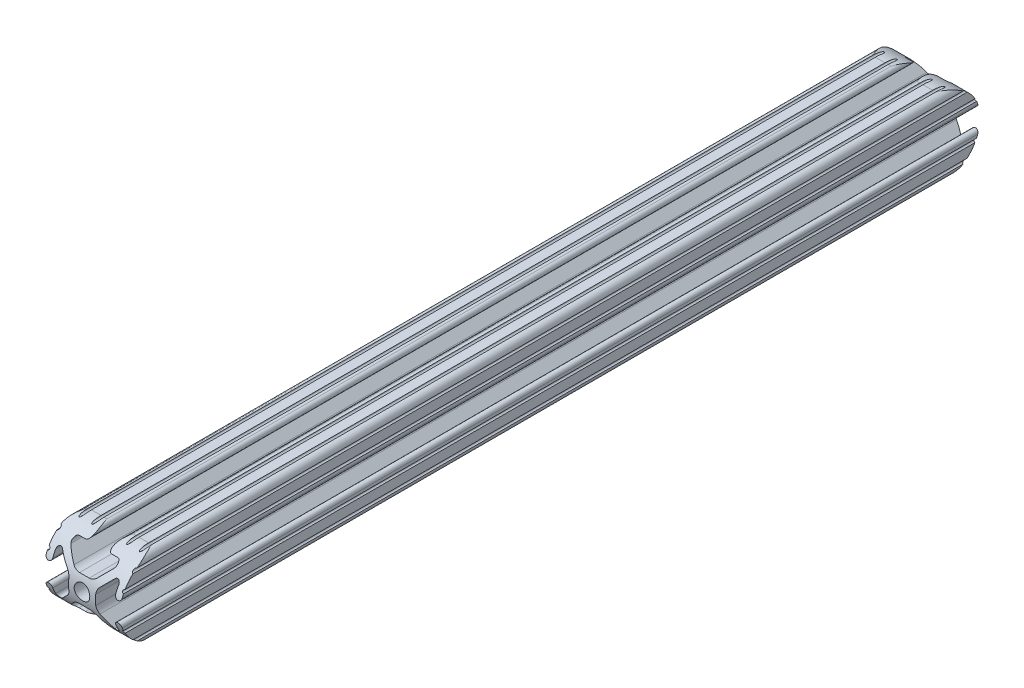
from build123d import *

# Parameters (mm, degrees)
SKETCH1_R           = 2.6035
BOSS_EXTRUDE1_DEPTH = 287.02
CUT_EXTRUDE1_DEPTH  = 26.4


with BuildPart() as part:
    # Sketch1 → Boss-Extrude1 (new body)
    with BuildSketch(Plane(origin=(0, 0, -450.85), x_dir=(-1, 0, 0), z_dir=(0, 0, -1))):
        with BuildLine():
            Line((12.7, -9.5504), (12.7, -6.3330836))
            ThreePointArc((12.7, -6.3330836), (12.192, -5.8250836), (12.7, -5.3170836))
            Line((12.7, -5.3170836), (12.7, -4.3434))
            ThreePointArc((12.7, -4.3434), (11.5951, -3.2385), (10.4902, -4.3434))
            Line((10.4902, -4.3434), (10.4902, -6.474794456))
            ThreePointArc((10.4902, -6.474794456), (9.863006367, -7.413456061), (8.75577951, -7.193214945))
            Line((8.75577951, -7.193214945), (5.42573597, -3.863171405))
            ThreePointArc((5.42573597, -3.863171405), (4.737482484, -2.833127272), (4.4958, -1.618107374))
            Line((4.4958, -1.618107374), (4.4958, 1.618107374))
            ThreePointArc((4.4958, 1.618107374), (4.737482484, 2.833127272), (5.42573597, 3.863171405))
            Line((5.42573597, 3.863171405), (8.75577951, 7.193214945))
            ThreePointArc((8.75577951, 7.193214945), (9.863006367, 7.413456061), (10.4902, 6.474794456))
            Line((10.4902, 6.474794456), (10.4902, 4.343399971))
            ThreePointArc((10.4902, 4.343399971), (11.5951, 3.238499971), (12.7, 4.343399971))
            Line((12.7, 4.343399971), (12.7, 5.3170836))
            ThreePointArc((12.7, 5.3170836), (12.192, 5.8250836), (12.7, 6.3330836))
            Line((12.7, 6.3330836), (12.7, 9.5504))
            ThreePointArc((12.7, 9.5504), (12.192000006, 10.058323491), (12.699846982, 10.566399977))
            ThreePointArc((12.699846982, 10.566399977), (12.082522516, 12.082522516), (10.566399977, 12.699846982))
            ThreePointArc((10.566399977, 12.699846982), (10.058323491, 12.192000006), (9.5504, 12.7))
            Line((9.5504, 12.7), (6.3330836, 12.7))
            ThreePointArc((6.3330836, 12.7), (5.8250836, 12.192), (5.3170836, 12.7))
            Line((5.3170836, 12.7), (4.3434, 12.7))
            ThreePointArc((4.3434, 12.7), (3.2385, 11.5951), (4.3434, 10.4902))
            Line((4.3434, 10.4902), (6.474794456, 10.4902))
            ThreePointArc((6.474794456, 10.4902), (7.413456061, 9.863006367), (7.193214945, 8.75577951))
            Line((7.193214945, 8.75577951), (3.863171405, 5.42573597))
            ThreePointArc((3.863171405, 5.42573597), (2.833127272, 4.737482484), (1.618107374, 4.4958))
            Line((1.618107374, 4.4958), (-1.618107374, 4.4958))
            ThreePointArc((-1.618107374, 4.4958), (-2.833127272, 4.737482484), (-3.863171405, 5.42573597))
            Line((-3.863171405, 5.42573597), (-7.193214945, 8.75577951))
            ThreePointArc((-7.193214945, 8.75577951), (-7.413456061, 9.863006367), (-6.474794456, 10.4902))
            Line((-6.474794456, 10.4902), (-4.343399971, 10.4902))
            ThreePointArc((-4.343399971, 10.4902), (-3.238499971, 11.5951), (-4.343399971, 12.7))
            Line((-4.343399971, 12.7), (-5.3170836, 12.7))
            ThreePointArc((-5.3170836, 12.7), (-5.8250836, 12.192), (-6.3330836, 12.7))
            Line((-6.3330836, 12.7), (-9.5504, 12.7))
            ThreePointArc((-9.5504, 12.7), (-10.058323491, 12.192000006), (-10.566399977, 12.699846982))
            ThreePointArc((-10.566399977, 12.699846982), (-12.082522516, 12.082522516), (-12.699846982, 10.566399977))
            ThreePointArc((-12.699846982, 10.566399977), (-12.192000006, 10.058323491), (-12.7, 9.5504))
            Line((-12.7, 9.5504), (-12.7, 6.3330836))
            ThreePointArc((-12.7, 6.3330836), (-12.192, 5.8250836), (-12.7, 5.3170836))
            Line((-12.7, 5.3170836), (-12.7, 4.3434))
            ThreePointArc((-12.7, 4.3434), (-11.5951, 3.2385), (-10.4902, 4.3434))
            Line((-10.4902, 4.3434), (-10.4902, 6.474794456))
            ThreePointArc((-10.4902, 6.474794456), (-9.863006367, 7.413456061), (-8.75577951, 7.193214945))
            Line((-8.75577951, 7.193214945), (-5.42573597, 3.863171405))
            ThreePointArc((-5.42573597, 3.863171405), (-4.737482484, 2.833127272), (-4.4958, 1.618107374))
            Line((-4.4958, 1.618107374), (-4.4958, -1.618107374))
            ThreePointArc((-4.4958, -1.618107374), (-4.737482484, -2.833127272), (-5.42573597, -3.863171405))
            Line((-5.42573597, -3.863171405), (-8.75577951, -7.193214945))
            ThreePointArc((-8.75577951, -7.193214945), (-9.863006367, -7.413456061), (-10.4902, -6.474794456))
            Line((-10.4902, -6.474794456), (-10.4902, -4.343399971))
            ThreePointArc((-10.4902, -4.343399971), (-11.5951, -3.238499971), (-12.7, -4.343399971))
            Line((-12.7, -4.343399971), (-12.7, -5.3170836))
            ThreePointArc((-12.7, -5.3170836), (-12.192, -5.8250836), (-12.7, -6.3330836))
            Line((-12.7, -6.3330836), (-12.7, -9.5504))
            ThreePointArc((-12.7, -9.5504), (-12.192000006, -10.058323491), (-12.699846982, -10.566399977))
            ThreePointArc((-12.699846982, -10.566399977), (-12.082522516, -12.082522516), (-10.566399977, -12.699846982))
            ThreePointArc((-10.566399977, -12.699846982), (-10.058323491, -12.192000006), (-9.5504, -12.7))
            Line((-9.5504, -12.7), (-6.3330836, -12.7))
            ThreePointArc((-6.3330836, -12.7), (-5.8250836, -12.192), (-5.3170836, -12.7))
            Line((-5.3170836, -12.7), (-4.3434, -12.7))
            ThreePointArc((-4.3434, -12.7), (-3.2385, -11.5951), (-4.3434, -10.4902))
            Line((-4.3434, -10.4902), (-6.474794456, -10.4902))
            ThreePointArc((-6.474794456, -10.4902), (-7.413456061, -9.863006367), (-7.193214945, -8.75577951))
            Line((-7.193214945, -8.75577951), (-3.863171405, -5.42573597))
            ThreePointArc((-3.863171405, -5.42573597), (-2.833127272, -4.737482484), (-1.618107374, -4.4958))
            Line((-1.618107374, -4.4958), (1.618107374, -4.4958))
            ThreePointArc((1.618107374, -4.4958), (2.833127272, -4.737482484), (3.863171405, -5.42573597))
            Line((3.863171405, -5.42573597), (7.193214945, -8.75577951))
            ThreePointArc((7.193214945, -8.75577951), (7.413456061, -9.863006367), (6.474794456, -10.4902))
            Line((6.474794456, -10.4902), (4.343399971, -10.4902))
            ThreePointArc((4.343399971, -10.4902), (3.238499971, -11.5951), (4.343399971, -12.7))
            Line((4.343399971, -12.7), (5.3170836, -12.7))
            ThreePointArc((5.3170836, -12.7), (5.8250836, -12.192), (6.3330836, -12.7))
            Line((6.3330836, -12.7), (9.5504, -12.7))
            ThreePointArc((9.5504, -12.7), (10.058323491, -12.192000006), (10.566399977, -12.699846982))
            ThreePointArc((10.566399977, -12.699846982), (12.082522516, -12.082522516), (12.699846982, -10.566399977))
            ThreePointArc((12.699846982, -10.566399977), (12.192000006, -10.058323491), (12.7, -9.5504))
        make_face()
        Circle(SKETCH1_R, mode=Mode.SUBTRACT)
    extrude(amount=-BOSS_EXTRUDE1_DEPTH)

    # Sketch3 → Cut-Extrude1 (cut, through all)
    with BuildSketch(Plane.ZY.offset(12.7)):
        with BuildLine():
            Line((-438.150153018, -12.699846982), (-438.150153018, -16.266210884))
            Line((-438.150153018, -16.266210884), (-458.591740555, -16.266210884))
            Line((-458.591740555, -16.266210884), (-458.591740555, 14.946399978))
            Line((-458.591740555, 14.946399978), (-438.150153018, 14.946399978))
            Line((-438.150153018, 14.946399978), (-438.150153018, 12.699846982))
            ThreePointArc((-438.150153018, 12.699846982), (-450.85, 0), (-438.150153018, -12.699846982))
        make_face()
        with BuildLine():
            Line((-176.53, -12.7), (-176.53, -14.99360577))
            Line((-176.53, -14.99360577), (-109.620679281, -14.99360577))
            Line((-109.620679281, -14.99360577), (-109.620679281, 14.946399978))
            Line((-109.620679281, 14.946399978), (-176.53, 14.946399978))
            Line((-176.53, 14.946399978), (-176.53, 12.7))
            ThreePointArc((-176.53, 12.7), (-163.83, 0), (-176.53, -12.7))
        make_face()
    extrude(amount=-CUT_EXTRUDE1_DEPTH, mode=Mode.SUBTRACT)


solid = part.part
